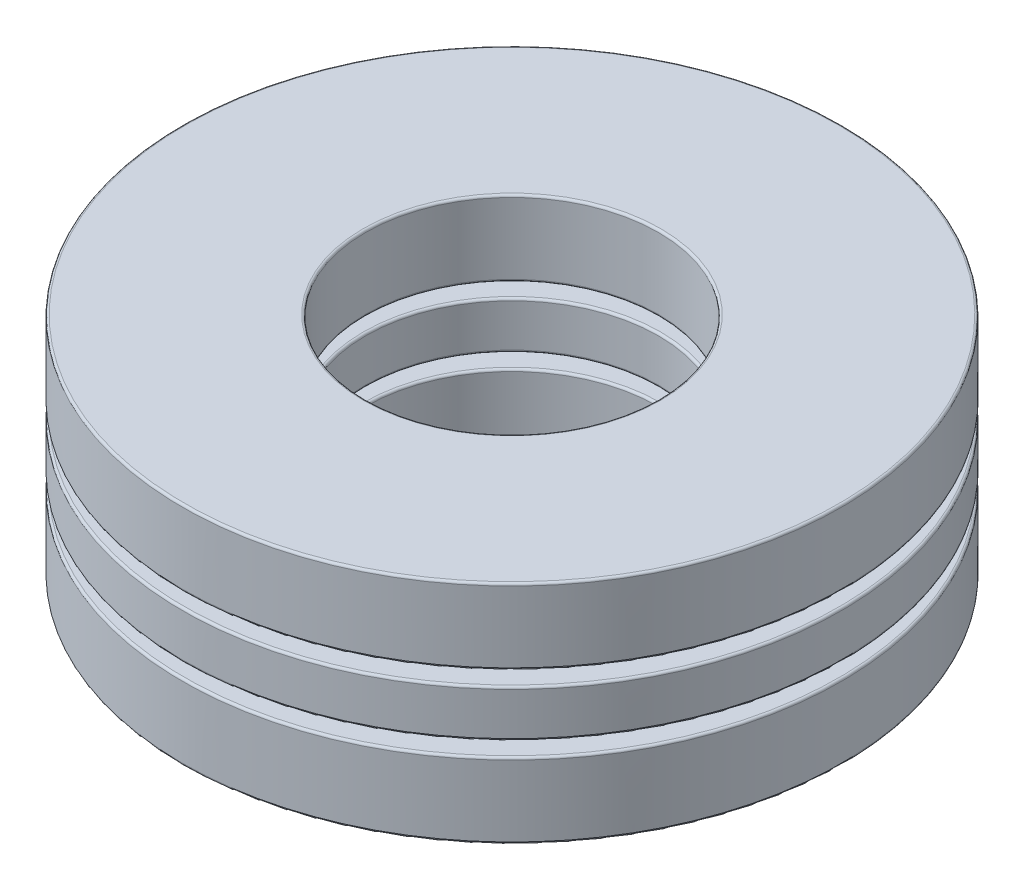
from build123d import *

# Parameters (mm, degrees)
SKETCH1_W         = 3.96875
SKETCH1_H         = 1.021291666
CIRPATTERN1_COUNT = 7
CIRPATTERN1_ANGLE = 308.571428571
CIRPATTERN2_COUNT = 7
SKETCH4_W         = 3.96875
SKETCH4_H         = 1.634066667
FILLET1_R         = 0.049022
FILLET2_R         = 0.049022
FILLET3_R         = 0.049022


with BuildPart() as part:
    # Sketch1 → Revolve1 (revolve)
    with BuildSketch(Plane(origin=(0, 0, 0), x_dir=(0, 0, -1), z_dir=(1, 0, 0))):
        with Locations((-5.159375, 0)):
            Rectangle(SKETCH1_W, SKETCH1_H)
    revolve(axis=Axis((0, -2.4511, 0), (0, 1, 0)))

    # Sketch3 → Cut-Revolve1 (revolve, cut)
    with BuildSketch(Plane(origin=(0, 0, 0), x_dir=(0, 0, -1), z_dir=(1, 0, 0))):
        with BuildLine():
            Line((-5.159375, 0.817033333), (-5.159375, -0.817033333))
            ThreePointArc((-5.159375, -0.817033333), (-5.976408333, 0), (-5.159375, 0.817033333))
        make_face()
    cut_revolve1 = revolve(axis=Axis((0, 0.817033333, 5.159375), (0, -1, 0)), mode=Mode.SUBTRACT)

    # CirPattern2: Cut-Revolve1 ×7 about axis
    cirpattern2_axis = Axis((0, 0, 0), (0, 1, 0))
    for i in range(1, CIRPATTERN2_COUNT):
        add(cut_revolve1.rotate(cirpattern2_axis, i * 360 / CIRPATTERN2_COUNT), mode=Mode.SUBTRACT)

    # Fillet2
    fillet2_edges = [part.edges().sort_by_distance(p)[0] for p in [
        (0, 0.510645833, -7.14375),
        (0, 0.510645833, -3.175),
        (0, -0.510645833, -3.175),
        (0, -0.510645833, -7.14375),
    ]]
    fillet(fillet2_edges, radius=FILLET2_R)


with BuildPart() as body_2:
    # Sketch2 → Revolve2 (revolve)
    with BuildSketch(Plane(origin=(0, 0, 0), x_dir=(0, 0, -1), z_dir=(1, 0, 0))):
        with BuildLine():
            Line((-5.159375, 0.817033333), (-5.159375, -0.817033333))
            ThreePointArc((-5.159375, -0.817033333), (-5.976408333, 0), (-5.159375, 0.817033333))
        make_face()
    revolve(axis=Axis((0, 0.817033333, 5.159375), (0, -1, 0)))


with BuildPart() as cirpattern1_1:
    # CirPattern1: pattern copy
    add(body_2.part.rotate(Axis((0, 2.4511, 0), (0, -1, 0)), 1 * CIRPATTERN1_ANGLE / (CIRPATTERN1_COUNT - 1)))


with BuildPart() as cirpattern1_2:
    # CirPattern1: pattern copy
    add(body_2.part.rotate(Axis((0, 2.4511, 0), (0, -1, 0)), 2 * CIRPATTERN1_ANGLE / (CIRPATTERN1_COUNT - 1)))


with BuildPart() as cirpattern1_3:
    # CirPattern1: pattern copy
    add(body_2.part.rotate(Axis((0, 2.4511, 0), (0, -1, 0)), 3 * CIRPATTERN1_ANGLE / (CIRPATTERN1_COUNT - 1)))


with BuildPart() as cirpattern1_4:
    # CirPattern1: pattern copy
    add(body_2.part.rotate(Axis((0, 2.4511, 0), (0, -1, 0)), 4 * CIRPATTERN1_ANGLE / (CIRPATTERN1_COUNT - 1)))


with BuildPart() as cirpattern1_5:
    # CirPattern1: pattern copy
    add(body_2.part.rotate(Axis((0, 2.4511, 0), (0, -1, 0)), 5 * CIRPATTERN1_ANGLE / (CIRPATTERN1_COUNT - 1)))


with BuildPart() as cirpattern1_6:
    # CirPattern1: pattern copy
    add(body_2.part.rotate(Axis((0, 2.4511, 0), (0, -1, 0)), 6 * CIRPATTERN1_ANGLE / (CIRPATTERN1_COUNT - 1)))


with BuildPart() as body_9:
    # Sketch4 → Revolve3 (revolve)
    with BuildSketch(Plane(origin=(0, 0, 0), x_dir=(0, 0, -1), z_dir=(1, 0, 0))):
        with Locations((-5.159375, 1.634066667)):
            Rectangle(SKETCH4_W, SKETCH4_H)
        with Locations((-5.159375, -1.634066667)):
            Rectangle(SKETCH4_W, SKETCH4_H)
    revolve(axis=Axis((0, -2.4511, 0), (0, 1, 0)))

    # Fillet1
    fillet1_edges = [body_9.edges().sort_by_distance(p)[0] for p in [
        (0, 0.817033333, -7.14375),
        (0, 0.817033333, -3.175),
        (0, 2.4511, -3.175),
        (0, 2.4511, -7.14375),
    ]]
    fillet(fillet1_edges, radius=FILLET1_R)

    # Fillet3
    fillet3_edges = [body_9.edges().sort_by_distance(p)[0] for p in [
        (0, -2.4511, -7.14375),
        (0, -2.4511, -3.175),
        (0, -0.817033333, -3.175),
        (0, -0.817033333, -7.14375),
    ]]
    fillet(fillet3_edges, radius=FILLET3_R)


solid = Compound([part.part, body_2.part, cirpattern1_1.part, cirpattern1_2.part, cirpattern1_3.part, cirpattern1_4.part, cirpattern1_5.part, cirpattern1_6.part, body_9.part])
